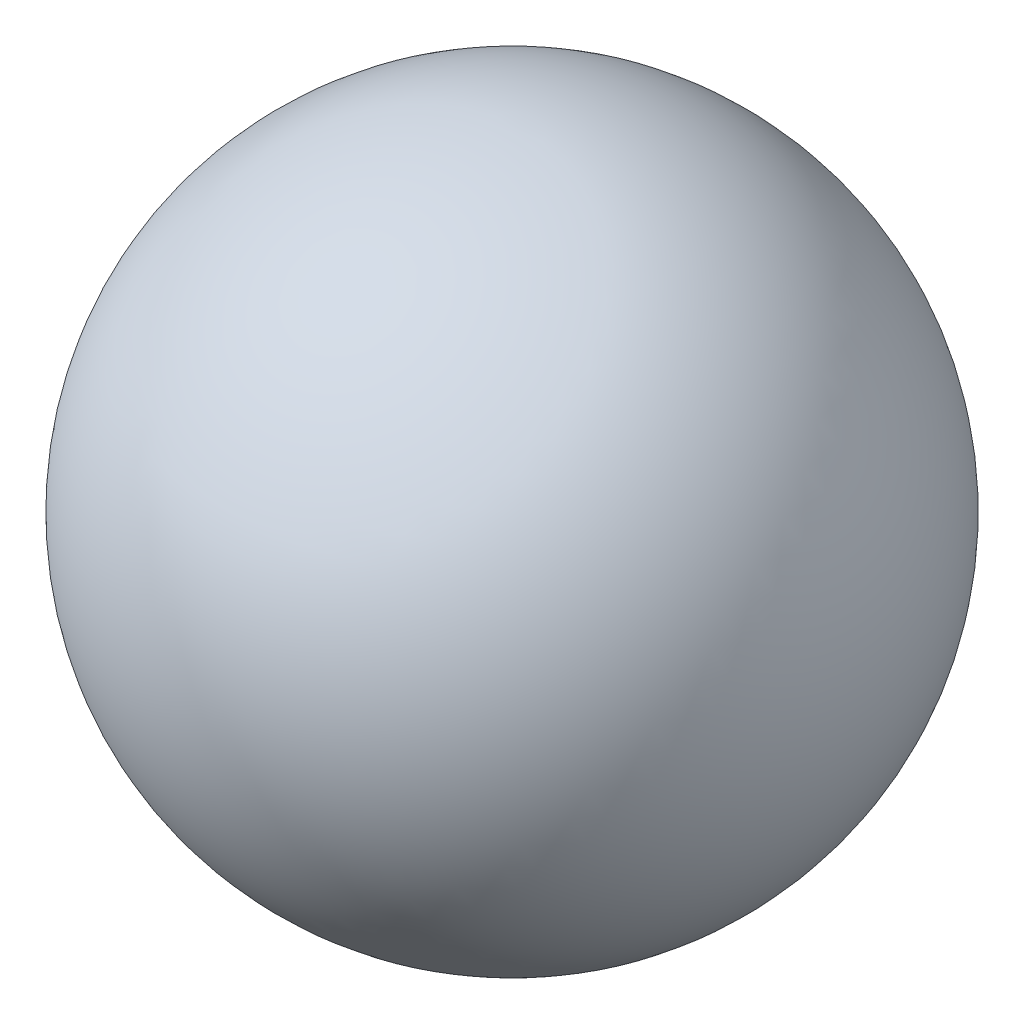
from build123d import *


with BuildPart() as part:
    # Sketch1 → Revolve1 (revolve)
    with BuildSketch(Plane.XY):
        with BuildLine():
            Line((0, -1.19), (0, 1.19))
            ThreePointArc((0, 1.19), (1.19, 0), (0, -1.19))
        make_face()
    revolve(axis=Axis((0, 1.19, 0), (0, -1, 0)))


solid = part.part
